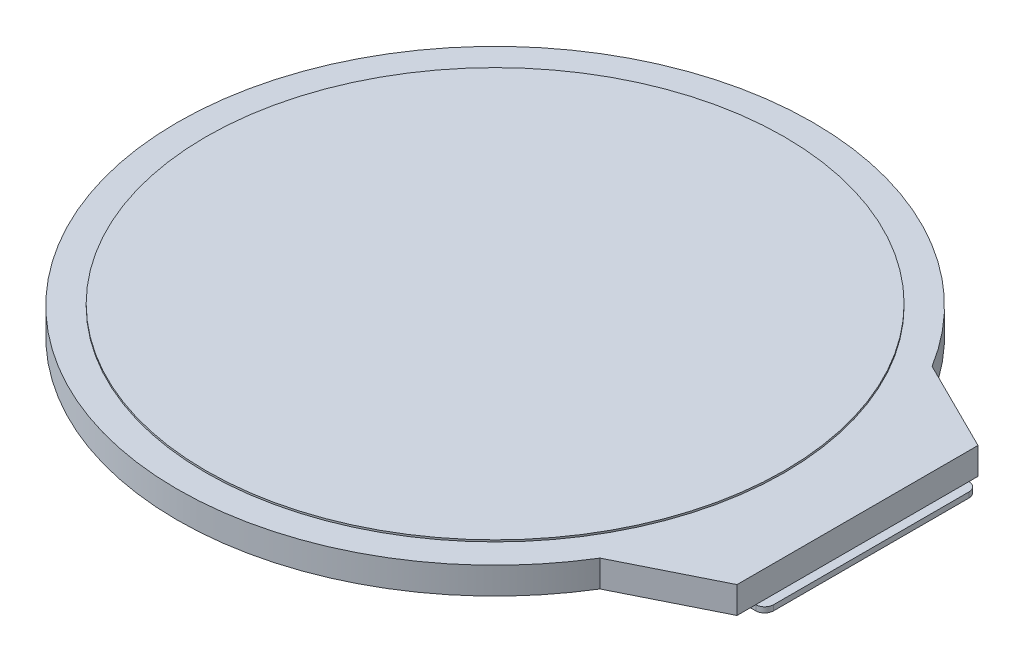
from build123d import *

# Parameters (mm, degrees)
EXTRUDE_1_DEPTH = 1.5
SKETCH_3_R      = 16.2
EXTRUDE_2_DEPTH = 0.1
EXTRUDE_3_DEPTH = 0.3
FILLET_1_R      = 0.5


with BuildPart() as part:
    # 草图1 → 凸台-拉伸1 (new body)
    with BuildSketch(Plane(origin=(0, 0, 0), x_dir=(1, 0, 0), z_dir=(0, 1, 0))):
        with BuildLine():
            Line((20.3, 6.75), (20.3, -6.75))
            Line((20.3, -6.75), (15.17728566, -9.3))
            ThreePointArc((15.17728566, -9.3), (-17.8, 0), (15.17728566, 9.3))
            Line((15.17728566, 9.3), (20.3, 6.75))
        make_face()
    extrude(amount=EXTRUDE_1_DEPTH)

    # 草图3 → 凸台-拉伸2 (add)
    with BuildSketch(Plane(origin=(0, 1.5, 0), x_dir=(1, 0, 0), z_dir=(0, 1, 0))):
        Circle(SKETCH_3_R)
    extrude(amount=EXTRUDE_2_DEPTH)

    # 草图4 → 凸台-拉伸3 (add)
    with BuildSketch(Plane.XZ):
        Polygon((20.8, -6.24), (20.8, 5.7), (10.06, 5.7), (10.06, -5.7), (13.26, -5.7), (13.8, -6.24), align=None)
        with BuildLine():
            add(Edge.make_bspline(
                [(10.818486802, -4.395328042), (10.805172896, -4.40810149), (10.777735498, -4.434425106), (10.731585338, -4.471001471), (10.680718947, -4.50727864), (10.644265505, -4.529889796), (10.625504346, -4.541526873)],
                knots=[0, 0, 0, 0, 5.5324e-05, 0.000114012, 0.000176454, 0.000242669, 0.000242669, 0.000242669, 0.000242669], degree=3))
            Line((10.625504346, -4.541526873), (10.625504346, -4.430415762))
            add(Edge.make_bspline(
                [(10.625504346, -4.430415762), (10.637511845, -4.422097374), (10.661358973, -4.405576894), (10.695199347, -4.378706463), (10.727916327, -4.35134661), (10.758520561, -4.322379824), (10.787985268, -4.292793589), (10.815334495, -4.261758783), (10.841379972, -4.22987118), (10.857300173, -4.207631606), (10.865270428, -4.196497633)],
                knots=[0, 0, 0, 0, 4.381e-05, 8.7008e-05, 0.000129577, 0.000171717, 0.000213376, 0.0002548, 0.000295763, 0.000336832, 0.000336832, 0.000336832, 0.000336832], degree=3))
            Line((10.865270428, -4.196497633), (10.935445867, -4.196497633))
            Line((10.935445867, -4.196497633), (10.935445867, -5.202345586))
            Line((10.935445867, -5.202345586), (10.818486802, -5.202345586))
            Line((10.818486802, -5.202345586), (10.818486802, -4.395328042))
        make_face(mode=Mode.SUBTRACT)
        with BuildLine():
            add(Edge.make_bspline(
                [(10.747897656, 4.993028455), (10.734583749, 4.980255007), (10.707146352, 4.953931392), (10.660996192, 4.917355027), (10.610129801, 4.881077858), (10.573676359, 4.858466702), (10.5549152, 4.846829625)],
                knots=[0, 0, 0, 0, 5.5324e-05, 0.000114012, 0.000176454, 0.000242669, 0.000242669, 0.000242669, 0.000242669], degree=3))
            Line((10.5549152, 4.846829625), (10.5549152, 4.957940736))
            add(Edge.make_bspline(
                [(10.5549152, 4.957940736), (10.566922699, 4.966259124), (10.590769826, 4.982779604), (10.6246102, 5.009650034), (10.65732718, 5.037009887), (10.687931415, 5.065976673), (10.717396122, 5.095562908), (10.744745348, 5.126597715), (10.770790825, 5.158485318), (10.786711026, 5.180724892), (10.794681281, 5.191858864)],
                knots=[0, 0, 0, 0, 4.381e-05, 8.7008e-05, 0.000129577, 0.000171717, 0.000213376, 0.0002548, 0.000295763, 0.000336832, 0.000336832, 0.000336832, 0.000336832], degree=3))
            Line((10.794681281, 5.191858864), (10.86485672, 5.191858864))
            Line((10.86485672, 5.191858864), (10.86485672, 4.186010911))
            Line((10.86485672, 4.186010911), (10.747897656, 4.186010911))
            Line((10.747897656, 4.186010911), (10.747897656, 4.993028455))
        make_face(mode=Mode.SUBTRACT)
        with BuildLine():
            add(Edge.make_bspline(
                [(11.239125726, 4.209402724), (11.239833141, 4.216646412), (11.241239164, 4.23104361), (11.246176296, 4.252223765), (11.253123203, 4.272903106), (11.262262649, 4.29307236), (11.273547522, 4.312739702), (11.287428195, 4.331488732), (11.302928415, 4.350145808), (11.321465332, 4.367779976), (11.341452247, 4.386542756), (11.362154394, 4.408019092), (11.384577692, 4.431466047), (11.407813575, 4.457882847), (11.432843118, 4.486319526), (11.458703548, 4.517616287), (11.486012518, 4.551174546), (11.514003658, 4.586370362), (11.541434011, 4.621720239), (11.56671184, 4.65597954), (11.589699984, 4.687968259), (11.610212924, 4.717799327), (11.627704069, 4.745816407), (11.642893445, 4.771584725), (11.655854012, 4.795057685), (11.668787399, 4.823092213), (11.680993939, 4.855423395), (11.690565178, 4.892152564), (11.694914493, 4.926144912), (11.693204675, 4.957381602), (11.686490374, 4.98588729), (11.674759334, 5.011748614), (11.658296591, 5.035057433), (11.637248958, 5.054942362), (11.613257207, 5.071313574), (11.586558607, 5.082313299), (11.557991357, 5.087872292), (11.528104736, 5.087369351), (11.497980127, 5.082013566), (11.467969579, 5.072704256), (11.439039112, 5.058289936), (11.410696566, 5.040307531), (11.384436934, 5.017140759), (11.36135616, 4.988611831), (11.341721738, 4.954866078), (11.331926076, 4.929936265), (11.326845024, 4.917005063)],
                knots=[0, 0, 0, 0, 2.1814e-05, 4.3357e-05, 6.5069e-05, 8.7171e-05, 0.000109684, 0.000132949, 0.000157077, 0.000182347, 0.000209615, 0.000239329, 0.00027181, 0.000306939, 0.000344857, 0.000385456, 0.00042872, 0.000474656, 0.000520361, 0.000562944, 0.000602373, 0.000638538, 0.000671529, 0.000701432, 0.000728277, 0.000751921, 0.000794003, 0.000831773, 0.00086557, 0.000896375, 0.00092511, 0.00095293, 0.000981054, 0.00101016, 0.001039355, 0.001067712, 0.001096172, 0.001126062, 0.001156827, 0.001187721, 0.001219978, 0.001253501, 0.00128818, 0.001324511, 0.001363144, 0.00140478, 0.00140478, 0.00140478, 0.00140478], degree=3))
            Line((11.326845024, 4.917005063), (11.215733913, 4.934548923))
            add(Edge.make_bspline(
                [(11.215733913, 4.934548923), (11.219656813, 4.945425545), (11.227289073, 4.966586728), (11.240431556, 4.996719226), (11.254008051, 5.024768665), (11.268391205, 5.050549193), (11.283893055, 5.073876788), (11.300137608, 5.094978241), (11.317197246, 5.113850725), (11.335137556, 5.130472165), (11.35389693, 5.145124772), (11.373604192, 5.157831984), (11.394013956, 5.168932074), (11.415206508, 5.178352557), (11.43722761, 5.185944542), (11.460175176, 5.191465532), (11.483814494, 5.195748716), (11.499956502, 5.19704853), (11.508131574, 5.197706818)],
                knots=[0, 0, 0, 0, 3.4679e-05, 6.747e-05, 9.8564e-05, 0.000128143, 0.000155956, 0.000182513, 0.000207966, 0.000232182, 0.000255794, 0.000279284, 0.000302447, 0.000325428, 0.000348785, 0.000372214, 0.000396178, 0.000420768, 0.000420768, 0.000420768, 0.000420768], degree=3))
            add(Edge.make_bspline(
                [(11.508131574, 5.197706818), (11.517654805, 5.198470616), (11.536175647, 5.199956055), (11.563321528, 5.200235741), (11.588939793, 5.198463956), (11.613483722, 5.195099015), (11.637461864, 5.189150579), (11.661491911, 5.180373219), (11.685801114, 5.168509643), (11.710349938, 5.153958828), (11.73441354, 5.136146543), (11.756199385, 5.11374856), (11.775424492, 5.087198528), (11.792601639, 5.05716399), (11.806466377, 5.023396102), (11.814804628, 4.985783772), (11.817862258, 4.944983333), (11.816182176, 4.908994618), (11.812089602, 4.878541375), (11.806355457, 4.854202585), (11.798091587, 4.828865854), (11.788361792, 4.802138754), (11.775441683, 4.774655097), (11.760899169, 4.745824926), (11.74350862, 4.716170927), (11.727726825, 4.690551343), (11.713428345, 4.669220128), (11.70145212, 4.651813704), (11.688368763, 4.633233154), (11.673683781, 4.613773904), (11.658174582, 4.592989779), (11.641491734, 4.571060318), (11.623490026, 4.548175641), (11.604377689, 4.524045702), (11.584068424, 4.498734851), (11.562470569, 4.472389765), (11.539590091, 4.445069691), (11.51578304, 4.416404416), (11.490759524, 4.386634205), (11.46450038, 4.355787108), (11.436918885, 4.324002126), (11.418239887, 4.302325786), (11.408716369, 4.291274069)],
                knots=[0, 0, 0, 0, 2.8656e-05, 5.5731e-05, 8.1347e-05, 0.000105638, 0.000129959, 0.000155311, 0.000182241, 0.000210992, 0.000240838, 0.000271776, 0.00030431, 0.000338939, 0.000375378, 0.000413366, 0.000453999, 0.000497793, 0.000521195, 0.000546098, 0.000572677, 0.000601119, 0.000631359, 0.000663713, 0.000697965, 0.000734447, 0.00075397, 0.000774997, 0.000797834, 0.000822135, 0.000848126, 0.000875634, 0.000904794, 0.000935474, 0.000967981, 0.001002147, 0.001037671, 0.001074887, 0.001113934, 0.001154341, 0.001196417, 0.001240183, 0.001240183, 0.001240183, 0.001240183], degree=3))
            Line((11.408716369, 4.291274069), (11.829769001, 4.291274069))
            Line((11.829769001, 4.291274069), (11.829769001, 4.186010911))
            Line((11.829769001, 4.186010911), (11.239125726, 4.186010911))
            Line((11.239125726, 4.186010911), (11.239125726, 4.209402724))
        make_face(mode=Mode.SUBTRACT)
    extrude(amount=EXTRUDE_3_DEPTH)

    # 圆角1
    fillet_1_edges = [part.edges().sort_by_distance(p)[0] for p in [
        (10.06, -0.15, -5.7),
        (10.06, -0.15, 5.7),
        (20.8, -0.15, 5.7),
        (20.8, -0.15, -6.24),
    ]]
    fillet(fillet_1_edges, radius=FILLET_1_R)


solid = part.part
